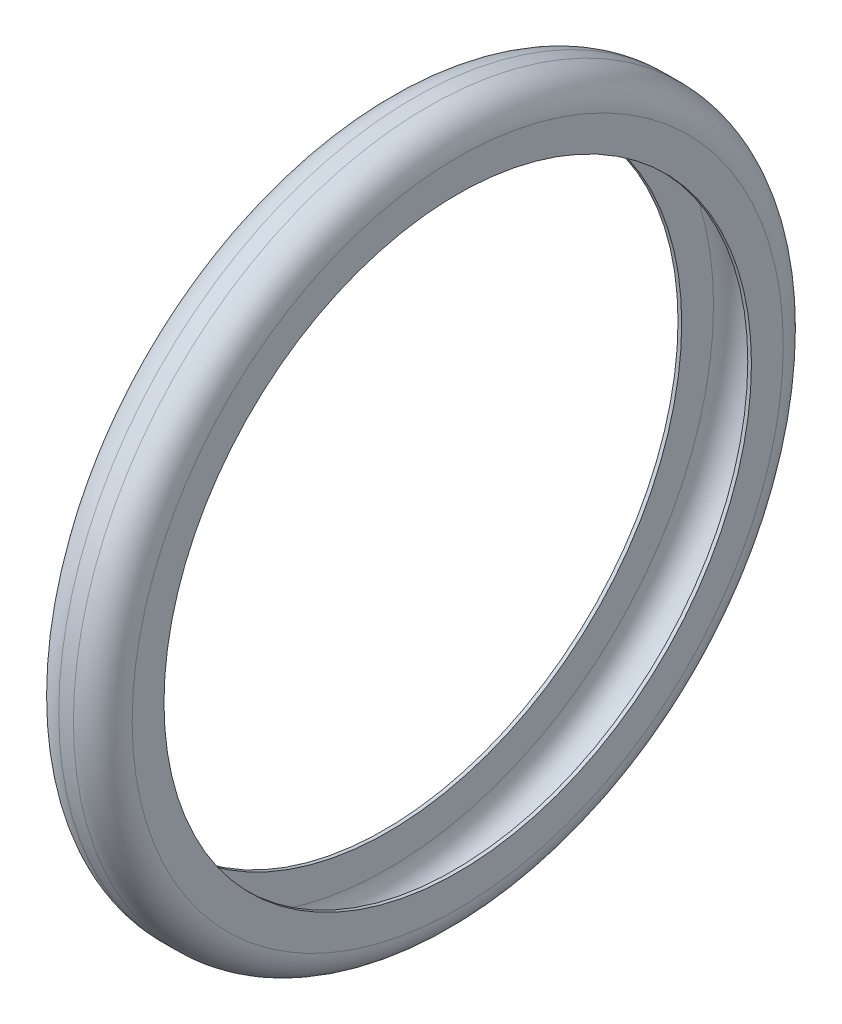
from build123d import *

# Parameters (mm, degrees)
SKETCH3_R           = 290
SKETCH3_R_2         = 240
BOSS_EXTRUDE1_DEPTH = 60
FILLET1_R           = 24
SHELL1_T            = -3


with BuildPart() as part:
    # Sketch3 → Boss-Extrude1 (new body)
    with BuildSketch(Plane(origin=(0, 0, 0), x_dir=(0, 0, -1), z_dir=(1, 0, 0))):
        Circle(SKETCH3_R)
        Circle(SKETCH3_R_2, mode=Mode.SUBTRACT)
    extrude(amount=BOSS_EXTRUDE1_DEPTH)

    # Fillet1
    fillet1_edges = [part.edges().sort_by_distance(p)[0] for p in [
        (0, 0, 290),
        (60, 0, 290),
    ]]
    fillet(fillet1_edges, radius=FILLET1_R)

    # Shell1
    shell1_openings = [part.faces().sort_by_distance(p)[0] for p in [
        (30, 0, 240),
    ]]
    offset(amount=SHELL1_T, openings=shell1_openings, kind=Kind.INTERSECTION)


solid = part.part
